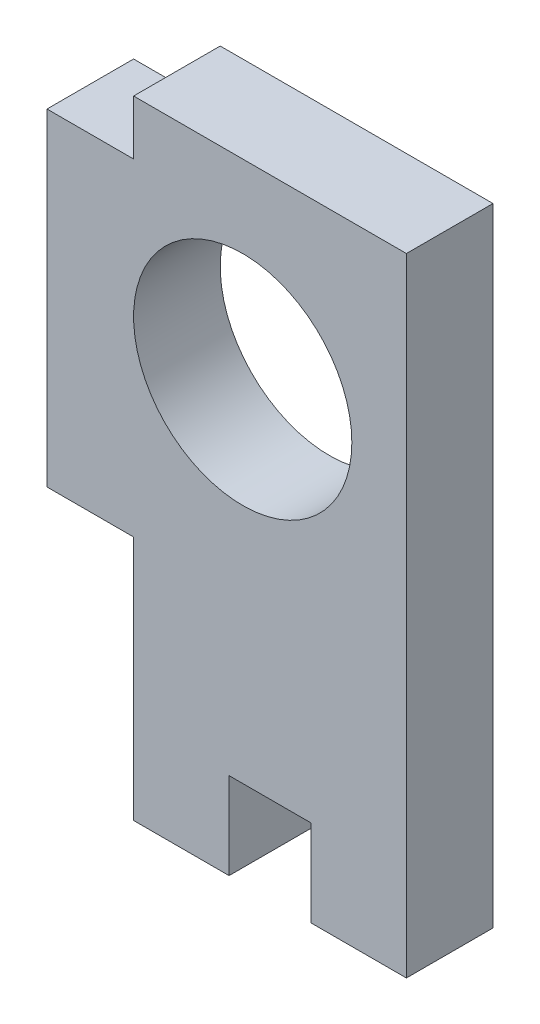
from build123d import *

# Parameters (mm, degrees)
SKETCH2_R           = 4
BOSS_EXTRUDE1_DEPTH = 3.175


with BuildPart() as part:
    # Sketch2 → Boss-Extrude1 (new body)
    with BuildSketch(Plane.XY):
        Polygon((-5, -11.5), (-1.5, -11.5), (-1.5, -8.325), (1.5, -8.325), (1.5, -11.5), (5, -11.5), (5, 11.5), (1.5, 11.5), (-1.5, 11.5), (-5, 11.5), (-5, 9.5), (-8.175, 9.5), (-8.175, -2.5), (-5, -2.5), align=None)
        with Locations((-1, 4.5)):
            Circle(SKETCH2_R, mode=Mode.SUBTRACT)
    extrude(amount=-BOSS_EXTRUDE1_DEPTH)


solid = part.part
